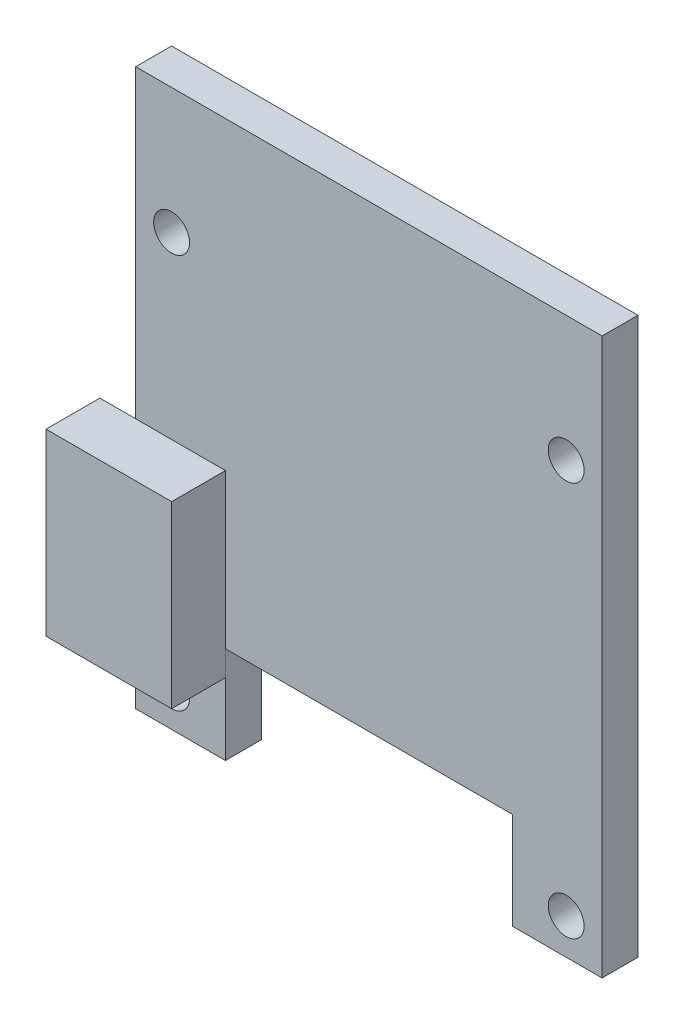
from build123d import *

# Parameters (mm, degrees)
SKETCH_1_W          = 5
SKETCH_1_H          = 4
EXTRUDE_1_DEPTH     = 2
EXTRUDE_START       = 2
SKETCH_1_3_W        = 2
SKETCH_1_3_H        = 10
EXTRUDE_2_DEPTH     = 3
SKETCH_2_R          = 1
CUT_EXTRUDE_1_DEPTH = 3


with BuildPart() as part:
    # Эскиз1 → Бобышка-Вытянуть1 (new body)
    with BuildSketch(Plane.XY):
        Polygon((-8, -1.5), (-8, -10.1), (8, -10.1), (8, -15.5), (13, -15.5), (13, 15.5), (-13, 15.5), (-13, -1.5), align=None)
        Polygon((-13, -11.5), (-8, -11.5), (-8, -10.1), (-8, -1.5), (-13, -1.5), align=None)
        with Locations((-10.5, -13.5)):
            Rectangle(SKETCH_1_W, SKETCH_1_H)
    extrude(amount=EXTRUDE_1_DEPTH)

    # Эскиз2 → Вырез-Вытянуть1 (cut, through all)
    with BuildSketch(Plane.XY.offset(2)):
        with Locations((11, -13.5)):
            Circle(SKETCH_2_R)
        with Locations((-11, -13.5)):
            Circle(SKETCH_2_R)
        with Locations((11, 8.5)):
            Circle(SKETCH_2_R)
        with Locations((-11, 8.5)):
            Circle(SKETCH_2_R)
    extrude(amount=-CUT_EXTRUDE_1_DEPTH, mode=Mode.SUBTRACT)


with BuildPart() as body_2:
    # Эскиз1<3> → Бобышка-Вытянуть2 (new body)
    with BuildSketch(Plane.XY.offset(EXTRUDE_START)):
        with Locations((-14, -6.5)):
            Rectangle(SKETCH_1_3_W, SKETCH_1_3_H)
        Polygon((-13, -11.5), (-8, -11.5), (-8, -10.1), (-8, -1.5), (-13, -1.5), align=None)
    extrude(amount=EXTRUDE_2_DEPTH)


solid = Compound([part.part, body_2.part])
